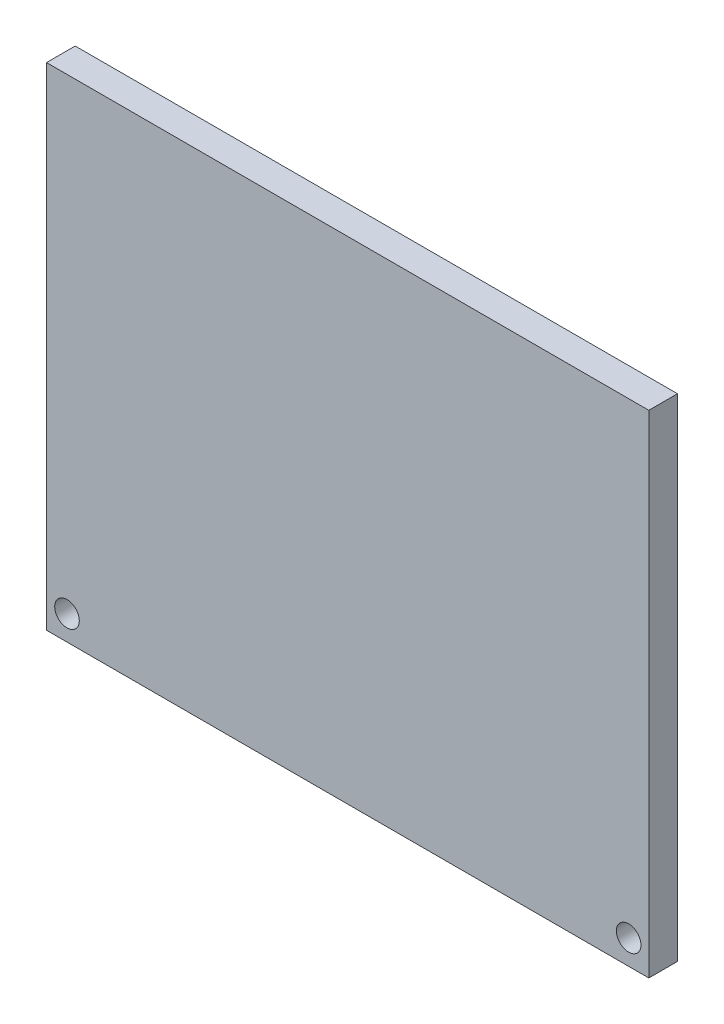
from build123d import *

# Parameters (mm, degrees)
ESBO_O1_W                = 147
ESBO_O1_H                = 120
ESBO_O1_R                = 3
RESSALTO_EXTRUS_O1_DEPTH = 7


with BuildPart() as part:
    # Esboço1 → Ressalto-extrusão1 (new body)
    with BuildSketch(Plane.XY):
        Rectangle(ESBO_O1_W, ESBO_O1_H)
        with Locations((-68.5, -54)):
            Circle(ESBO_O1_R, mode=Mode.SUBTRACT)
        with Locations((68.58, -54)):
            Circle(ESBO_O1_R, mode=Mode.SUBTRACT)
    extrude(amount=RESSALTO_EXTRUS_O1_DEPTH)


solid = part.part
